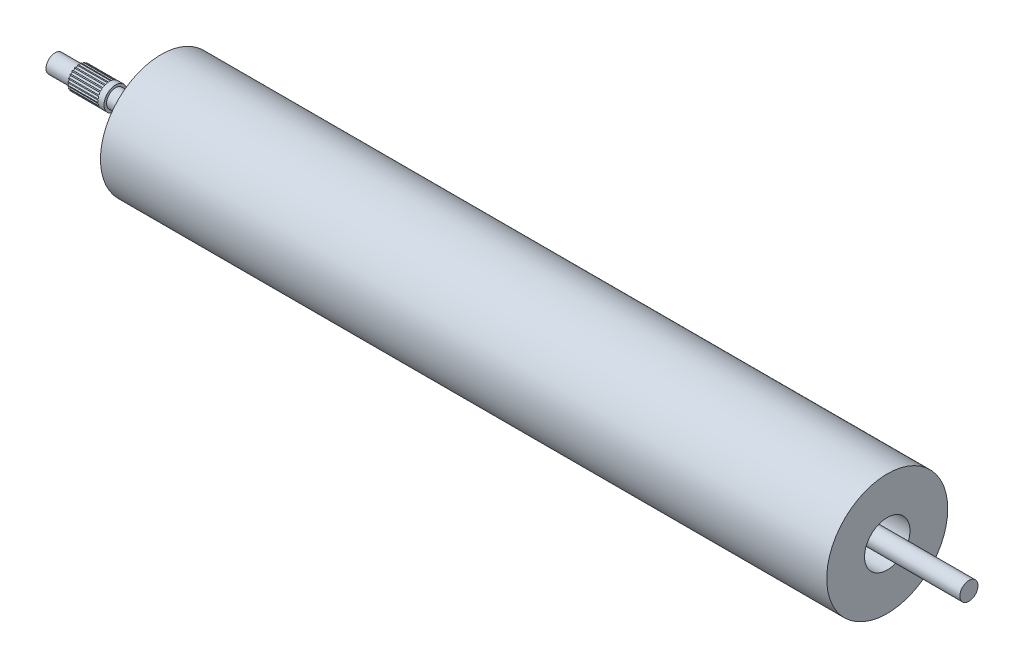
from build123d import *

# Parameters (mm, degrees)
SKETCH1_R                = 20
SKETCH1_R_2              = 7.5
BOSS_EXTRUDE1_DEPTH      = 240
SKETCH6_R                = 3
BOSS_EXTRUDE2_DEPTH      = 27
BOSS_EXTRUDE2_DEPTH_BACK = 275
SKETCH7_R                = 3.823623307
BOSS_EXTRUDE3_DEPTH      = 12
SKETCH8_R                = 0.346261595
CUT_EXTRUDE1_DEPTH       = 10


with BuildPart() as part:
    # Sketch1 → Boss-Extrude1 (new body)
    with BuildSketch(Plane(origin=(0, 0, 0), x_dir=(0, 0, -1), z_dir=(1, 0, 0))):
        Circle(SKETCH1_R)
        Circle(SKETCH1_R_2, mode=Mode.SUBTRACT)
    extrude(amount=BOSS_EXTRUDE1_DEPTH)


with BuildPart() as body_2:
    # Sketch6 → Boss-Extrude2 (new body, two sides)
    with BuildSketch(Plane(origin=(240, 0, 0), x_dir=(0, 0, -1), z_dir=(1, 0, 0))) as boss_extrude2_sk:
        Circle(SKETCH6_R)
    extrude(amount=BOSS_EXTRUDE2_DEPTH)
    extrude(boss_extrude2_sk.sketch, amount=-BOSS_EXTRUDE2_DEPTH_BACK)

    # Sketch7 → Boss-Extrude3 (add)
    with BuildSketch(Plane.ZY.offset(15)):
        Circle(SKETCH7_R)
    extrude(amount=BOSS_EXTRUDE3_DEPTH)

    # Sketch8 → Cut-Extrude1 (cut)
    with BuildSketch(Plane.ZY.offset(27)):
        with Locations((-3.823623307, 0)):
            Circle(SKETCH8_R)
        with Locations((-3.693336502, 0.989626533)):
            Circle(SKETCH8_R)
        with Locations((-3.311354918, 1.911811653)):
            Circle(SKETCH8_R)
        with Locations((-2.703709969, 2.703709969)):
            Circle(SKETCH8_R)
        with Locations((-1.911811653, 3.311354918)):
            Circle(SKETCH8_R)
        with Locations((-0.989626533, 3.693336502)):
            Circle(SKETCH8_R)
        with Locations((0, 3.823623307)):
            Circle(SKETCH8_R)
        with Locations((0.989626533, 3.693336502)):
            Circle(SKETCH8_R)
        with Locations((1.911811653, 3.311354918)):
            Circle(SKETCH8_R)
        with Locations((2.703709969, 2.703709969)):
            Circle(SKETCH8_R)
        with Locations((3.311354918, 1.911811653)):
            Circle(SKETCH8_R)
        with Locations((3.693336502, 0.989626533)):
            Circle(SKETCH8_R)
        with Locations((3.823623307, 0)):
            Circle(SKETCH8_R)
        with Locations((3.693336502, -0.989626533)):
            Circle(SKETCH8_R)
        with Locations((3.311354918, -1.911811653)):
            Circle(SKETCH8_R)
        with Locations((2.703709969, -2.703709969)):
            Circle(SKETCH8_R)
        with Locations((1.911811653, -3.311354918)):
            Circle(SKETCH8_R)
        with Locations((0.989626533, -3.693336502)):
            Circle(SKETCH8_R)
        with Locations((0, -3.823623307)):
            Circle(SKETCH8_R)
        with Locations((-0.989626533, -3.693336502)):
            Circle(SKETCH8_R)
        with Locations((-1.911811653, -3.311354918)):
            Circle(SKETCH8_R)
        with Locations((-2.703709969, -2.703709969)):
            Circle(SKETCH8_R)
        with Locations((-3.311354918, -1.911811653)):
            Circle(SKETCH8_R)
        with Locations((-3.693336502, -0.989626533)):
            Circle(SKETCH8_R)
    extrude(amount=-CUT_EXTRUDE1_DEPTH, mode=Mode.SUBTRACT)


solid = Compound([part.part, body_2.part])
